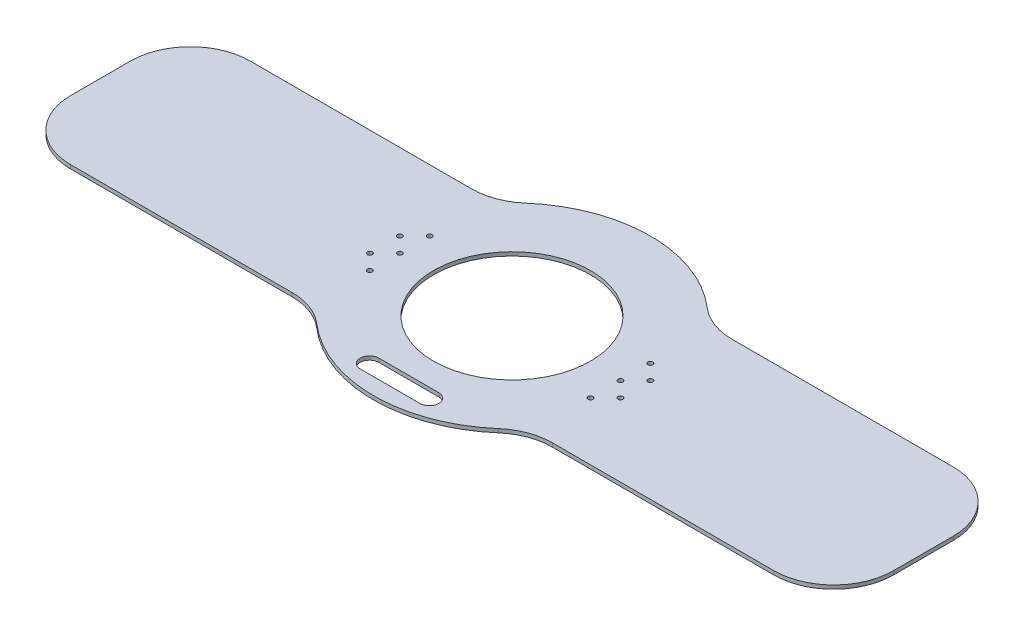
from build123d import *

# Parameters (mm, degrees)
SKETCH1_R           = 66.675
BOSS_EXTRUDE1_DEPTH = 3.175
CUT_EXTRUDE4_DEPTH  = 3.175
SKETCH10_R          = 2.0955
CUT_EXTRUDE7_DEPTH  = 4.175


with BuildPart() as part:
    # Sketch1 → Boss-Extrude1 (new body)
    with BuildSketch(Plane(origin=(0, 0, 0), x_dir=(1, 0, 0), z_dir=(0, 1, 0))):
        with BuildLine():
            Line((-110.396900432, 76.2), (-298.45, 76.2))
            ThreePointArc((-298.45, 76.2), (-334.371024484, 61.321024484), (-349.25, 25.4))
            Line((-349.25, 25.4), (-349.25, -25.4))
            ThreePointArc((-349.25, -25.4), (-334.371024484, -61.321024484), (-298.45, -76.2))
            Line((-298.45, -76.2), (-110.396900432, -76.2))
            ThreePointArc((-110.396900432, -76.2), (-92.606633854, -79.41695244), (-77.069534264, -88.660377358))
            ThreePointArc((-77.069534264, -88.660377358), (0, -117.475), (77.069534264, -88.660377358))
            ThreePointArc((77.069534264, -88.660377358), (92.606633854, -79.41695244), (110.396900432, -76.2))
            Line((110.396900432, -76.2), (298.45, -76.2))
            ThreePointArc((298.45, -76.2), (334.371024484, -61.321024484), (349.25, -25.4))
            Line((349.25, -25.4), (349.25, 25.4))
            ThreePointArc((349.25, 25.4), (334.371024484, 61.321024484), (298.45, 76.2))
            Line((298.45, 76.2), (110.396900432, 76.2))
            ThreePointArc((110.396900432, 76.2), (92.606633854, 79.41695244), (77.069534264, 88.660377358))
            ThreePointArc((77.069534264, 88.660377358), (0, 117.475), (-77.069534264, 88.660377358))
            ThreePointArc((-77.069534264, 88.660377358), (-92.606633854, 79.41695244), (-110.396900432, 76.2))
        make_face()
        Circle(SKETCH1_R, mode=Mode.SUBTRACT)
    extrude(amount=BOSS_EXTRUDE1_DEPTH)

    # Sketch7 → Cut-Extrude4 (cut)
    with BuildSketch(Plane(origin=(0, 3.175, 0), x_dir=(1, 0, 0), z_dir=(0, 1, 0))):
        with BuildLine():
            Line((-25.4, -87.56211469), (25.4, -87.56211469))
            ThreePointArc((25.4, -87.56211469), (33.3375, -95.49961469), (25.4, -103.43711469))
            Line((25.4, -103.43711469), (-25.4, -103.43711469))
            ThreePointArc((-25.4, -103.43711469), (-33.3375, -95.49961469), (-25.4, -87.56211469))
        make_face()
    extrude(amount=-CUT_EXTRUDE4_DEPTH, mode=Mode.SUBTRACT)

    # Sketch10 → Cut-Extrude7 (cut, through all)
    with BuildSketch(Plane(origin=(0, 3.175, 0), x_dir=(1, 0, 0), z_dir=(0, 1, 0))):
        with Locations((-93.6244, -26.9875)):
            Circle(SKETCH10_R)
        with Locations((-106.3244, -14.2875)):
            Circle(SKETCH10_R)
        with Locations((-93.6244, -1.5875)):
            Circle(SKETCH10_R)
        with Locations((-106.3244, 11.1125)):
            Circle(SKETCH10_R)
        with Locations((-93.6244, 23.8125)):
            Circle(SKETCH10_R)
        with Locations((93.6244, -26.9875)):
            Circle(SKETCH10_R)
        with Locations((106.3244, -14.2875)):
            Circle(SKETCH10_R)
        with Locations((93.6244, -1.5875)):
            Circle(SKETCH10_R)
        with Locations((106.3244, 11.1125)):
            Circle(SKETCH10_R)
        with Locations((93.6244, 23.8125)):
            Circle(SKETCH10_R)
    extrude(amount=-CUT_EXTRUDE7_DEPTH, mode=Mode.SUBTRACT)


solid = part.part
